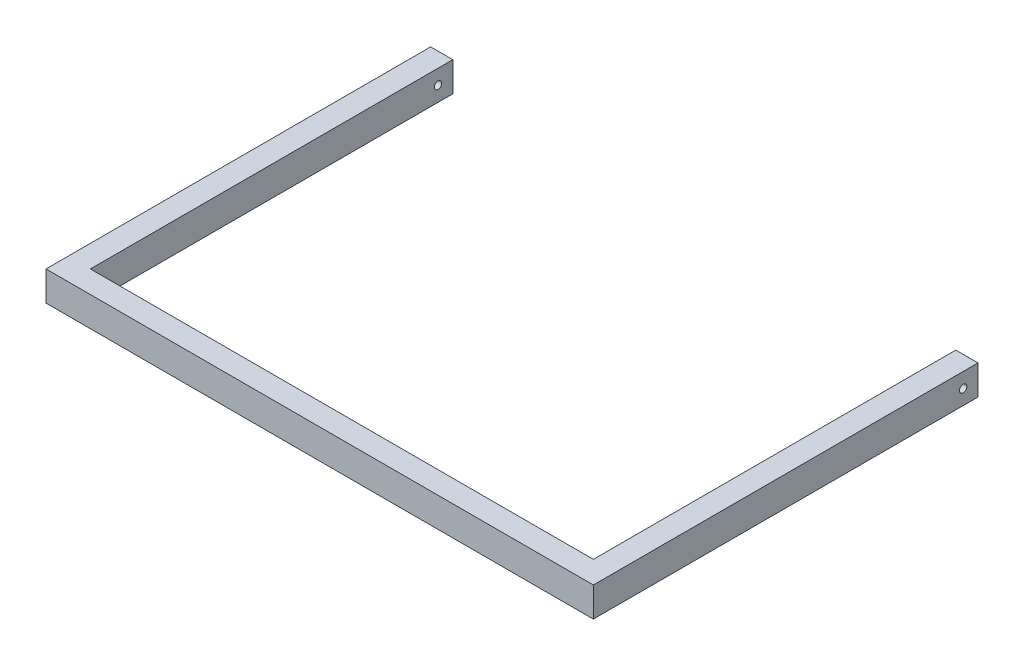
from build123d import *

# Parameters (mm, degrees)
EXTRUDE_1_DEPTH     = 40
SKETCH_2_R          = 5
CUT_EXTRUDE_1_DEPTH = 741


with BuildPart() as part:
    # Эскиз1 → Бобышка-Вытянуть1 (new body)
    with BuildSketch(Plane(origin=(0, 0, 0), x_dir=(1, 0, 0), z_dir=(0, 1, 0))):
        Polygon((1.532419628, 486.843020925), (1.532419628, -3.156979075), (681.532419628, -3.156979075), (681.532419628, 486.843020925), (711.532419628, 486.843020925), (711.532419628, -33.156979075), (-28.467580372, -33.156979075), (-28.467580372, 486.843020925), align=None)
    extrude(amount=EXTRUDE_1_DEPTH)

    # Эскиз2 → Вырез-Вытянуть1 (cut, through all)
    with BuildSketch(Plane(origin=(711.532419628, 0, 0), x_dir=(0, 0, -1), z_dir=(1, 0, 0))):
        with Locations((466.843020925, 20)):
            Circle(SKETCH_2_R)
    extrude(amount=-CUT_EXTRUDE_1_DEPTH, mode=Mode.SUBTRACT)


solid = part.part
